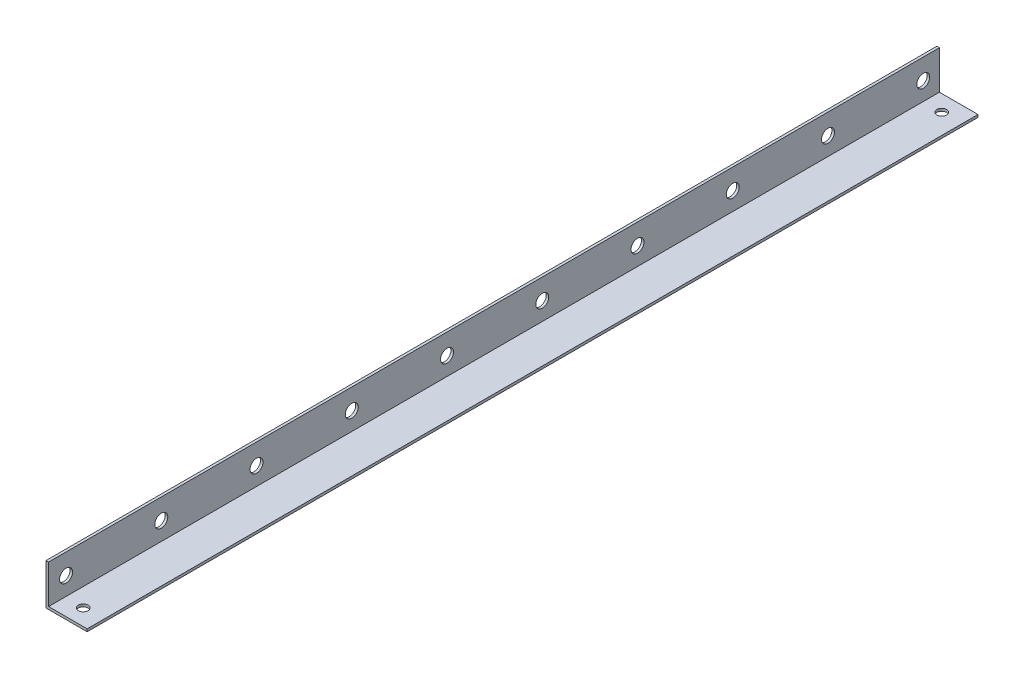
from build123d import *

# Parameters (mm, degrees)
BOSS_EXTRUDE1_DEPTH = 275
SKETCH2_R           = 4
CUT_EXTRUDE1_DEPTH  = 2.5875
CUT_EXTRUDE2_START  = -2.5875
SKETCH3_R           = 3
CUT_EXTRUDE2_DEPTH  = 27.4


with BuildPart() as part:
    # Sketch1 → Boss-Extrude1 (new body, symmetric)
    with BuildSketch(Plane.XY):
        Polygon((0, 0), (0, 25.4), (1.5875, 25.4), (1.5875, 1.5875), (25.4, 1.5875), (25.4, 0), align=None)
    extrude(amount=BOSS_EXTRUDE1_DEPTH, both=True)

    # Sketch2 → Cut-Extrude1 (cut, through all)
    with BuildSketch(Plane(origin=(1.5875, 0, 0), x_dir=(0, 0, -1), z_dir=(1, 0, 0))):
        with Locations((265, 12.7)):
            Circle(SKETCH2_R)
        with Locations((206.2, 12.7)):
            Circle(SKETCH2_R)
        with Locations((147.4, 12.7)):
            Circle(SKETCH2_R)
        with Locations((88.6, 12.7)):
            Circle(SKETCH2_R)
        with Locations((29.8, 12.7)):
            Circle(SKETCH2_R)
        with Locations((-29, 12.7)):
            Circle(SKETCH2_R)
        with Locations((-87.8, 12.7)):
            Circle(SKETCH2_R)
        with Locations((-146.6, 12.7)):
            Circle(SKETCH2_R)
        with Locations((-205.4, 12.7)):
            Circle(SKETCH2_R)
        with Locations((-264.2, 12.7)):
            Circle(SKETCH2_R)
    extrude(amount=-CUT_EXTRUDE1_DEPTH, mode=Mode.SUBTRACT)

    # Sketch3 → Cut-Extrude2 (cut)
    with BuildSketch(Plane(origin=(0, 1.5875, 0), x_dir=(1, 0, 0), z_dir=(0, 1, 0)).offset(CUT_EXTRUDE2_START)):
        with Locations((13, 265)):
            Circle(SKETCH3_R)
    cut_extrude2 = extrude(amount=CUT_EXTRUDE2_DEPTH, mode=Mode.SUBTRACT)

    # Mirror1: Cut-Extrude2 across plane
    add(cut_extrude2.mirror(Plane.XY), mode=Mode.SUBTRACT)


solid = part.part
